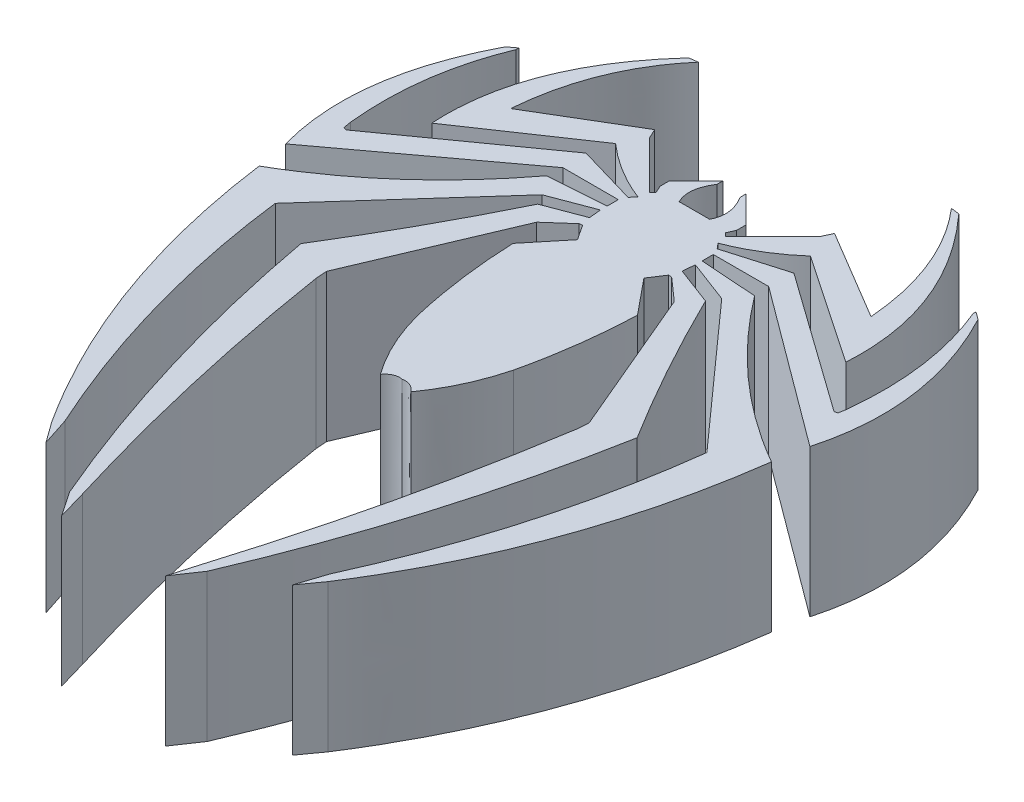
from build123d import *

# Parameters (mm, degrees)
BOSS_EXTRUDE1_DEPTH = 10


with BuildPart() as part:
    # Sketch1 → Boss-Extrude1 (new body)
    with BuildSketch(Plane(origin=(0, 0, 0), x_dir=(1, 0, 0), z_dir=(0, 1, 0))):
        with BuildLine():
            Line((-0.77475919, 17.805575817), (-0.77475919, 18.205472922))
            Line((-0.77475919, 18.205472922), (-2.591328104, 16.388904008))
            Line((-2.591328104, 16.388904008), (-2.591328104, 15.751300349))
            Line((-2.591328104, 15.751300349), (-2.362753208, 15.246029526))
            Line((-2.362753208, 15.246029526), (-2.591328104, 15.017454629))
            Line((-2.591328104, 15.017454629), (-5.779346397, 18.205472922))
            Line((-5.779346397, 18.205472922), (-6.095268046, 18.892889731))
            Line((-6.095268046, 18.892889731), (-12.218826377, 15.246029526))
            add(Edge.make_bspline(
                [(-12.218826377, 15.246029526), (-11.778721685, 20.620695324), (-8.581947184, 24.333309757)],
                knots=[0, 0, 0, 1, 1, 1], degree=2))
            Line((-8.581947184, 24.333309757), (-9.157047212, 24.259356466))
            add(Edge.make_bspline(
                [(-9.157047212, 24.259356466), (-14.447655818, 18.459017457), (-14.037673367, 11.71891231)],
                knots=[0, 0, 0, 1, 1, 1], degree=2))
            Line((-14.037673367, 11.71891231), (-6.606809824, 16.748676517))
            add(Edge.make_bspline(
                [(-6.606809824, 16.748676517), (-4.84160761, 15.196820639), (-2.713996128, 14.373140945)],
                knots=[0, 0, 0, 1, 1, 1], degree=2))
            Line((-2.713996128, 14.373140945), (-3.022885214, 14.011805458))
            Line((-3.022885214, 14.011805458), (-7.04843704, 15.185986651))
            Line((-7.04843704, 15.185986651), (-16.542260828, 8.414995079))
            Line((-16.542260828, 8.414995079), (-16.750184267, 8.475642613))
            Line((-16.750184267, 8.475642613), (-16.844000716, 8.999446115))
            add(Edge.make_bspline(
                [(-16.844000716, 8.999446115), (-17.398318859, 14.288056659), (-15.498292646, 18.892889731)],
                knots=[0, 0, 0, 0.937492037, 0.937492037, 0.937492037], degree=2))
            Line((-15.498292646, 18.892889731), (-15.498292646, 19.083480243))
            Line((-15.498292646, 19.083480243), (-16.018185643, 18.698181665))
            add(Edge.make_bspline(
                [(-16.018185643, 18.698181665), (-19.54860855, 11.964227915), (-17.772645014, 5.545401207)],
                knots=[0, 0, 0, 1, 1, 1], degree=2))
            Line((-17.772645014, 5.545401207), (-6.976425445, 13.546601594))
            Line((-6.976425445, 13.546601594), (-3.220749094, 13.546601594))
            Line((-3.220749094, 13.546601594), (-3.220749094, 12.787927187))
            Line((-3.220749094, 12.787927187), (-7.04843704, 12.523140875))
            add(Edge.make_bspline(
                [(-7.04843704, 12.523140875), (-11.378277138, 6.786058759), (-17.368277161, 3.344273399)],
                knots=[0, 0, 0, 1, 1, 1], degree=2))
            add(Edge.make_bspline(
                [(-17.368277161, 3.344273399), (-15.724066268, -8.863327627), (-9.366664211, -18.723496609)],
                knots=[0, 0, 0, 0.983877667, 0.983877667, 0.983877667], degree=2))
            Line((-9.366664211, -18.723496609), (-8.360846592, -20.115700618))
            Line((-8.360846592, -20.115700618), (-8.984631154, -18.211516166))
            add(Edge.make_bspline(
                [(-8.984631154, -18.211516166), (-13.367422275, -8.565356306), (-14.632198794, 1.702238546)],
                knots=[0, 0, 0, 0.96561084, 0.96561084, 0.96561084], degree=2))
            Line((-14.632198794, 1.702238546), (-6.095268046, 11.245692572))
            Line((-6.095268046, 11.245692572), (-3.220749094, 12.334656835))
            Line((-3.220749094, 12.334656835), (-3.137312332, 11.517506569))
            Line((-3.137312332, 11.517506569), (-5.68828216, 10.551113575))
            add(Edge.make_bspline(
                [(-5.68828216, 10.551113575), (-8.289822739, 5.230431142), (-11.398307003, 0.207327452)],
                knots=[0, 0, 0, 0.941866113, 0.941866113, 0.941866113], degree=2))
            add(Edge.make_bspline(
                [(-11.398307003, 0.207327452), (-9.259704318, -11.446844699), (-4.663293434, -22.207552312)],
                knots=[0, 0, 0, 0.984459997, 0.984459997, 0.984459997], degree=2))
            Line((-4.663293434, -22.207552312), (-3.52644295, -23.884260193))
            Line((-3.52644295, -23.884260193), (-4.094868192, -21.920639742))
            add(Edge.make_bspline(
                [(-4.094868192, -21.920639742), (-7.201743798, -11.767427454), (-8.842724338, -1.332659634)],
                knots=[0, 0, 0, 0.95775591, 0.95775591, 0.95775591], degree=2))
            Line((-8.842724338, -1.332659634), (-8.901419383, -0.55237788))
            Line((-8.901419383, -0.55237788), (-4.663293434, 9.459890703))
            Line((-4.663293434, 9.459890703), (-3.137312332, 10.808717055))
            Line((-3.137312332, 10.808717055), (-2.918598052, 10.825169375))
            Line((-2.918598052, 10.825169375), (-2.254002061, 9.809392881))
            Line((-2.254002061, 9.809392881), (-4.219363172, 7.408826128))
            add(Edge.make_bspline(
                [(-4.219363172, 7.408826128), (-4.079064375, 3.638553555), (-3.236682616, 0)],
                knots=[0, 0, 0, 0.892205795, 0.892205795, 0.892205795], degree=2))
            add(Edge.make_bspline(
                [(-3.236682616, 0), (-2.55670829, -2.640008962), (-1.031376318, -4.773443308)],
                knots=[0, 0, 0, 0.876843131, 0.876843131, 0.876843131], degree=2))
            add(Edge.make_bspline(
                [(-1.031376318, -4.773443308), (-0.582556801, -4.206513749), (0, -4.327217184)],
                knots=[0, 0, 0, 1, 1, 1], degree=2))
            add(Edge.make_bspline(
                [(1.031376318, -4.773443308), (0.582556801, -4.206513749), (0, -4.327217184)],
                knots=[0, 0, 0, 1, 1, 1], degree=2))
            add(Edge.make_bspline(
                [(3.236682616, 0), (2.55670829, -2.640008962), (1.031376318, -4.773443308)],
                knots=[0, 0, 0, 0.876843131, 0.876843131, 0.876843131], degree=2))
            add(Edge.make_bspline(
                [(4.219363172, 7.408826128), (4.079064375, 3.638553555), (3.236682616, 0)],
                knots=[0, 0, 0, 0.892205795, 0.892205795, 0.892205795], degree=2))
            Line((4.219363172, 7.408826128), (2.254002061, 9.809392881))
            Line((2.254002061, 9.809392881), (2.918598052, 10.825169375))
            Line((2.918598052, 10.825169375), (3.137312332, 10.808717055))
            Line((3.137312332, 10.808717055), (4.663293434, 9.459890703))
            Line((4.663293434, 9.459890703), (8.901419383, -0.55237788))
            Line((8.901419383, -0.55237788), (8.842724338, -1.332659634))
            add(Edge.make_bspline(
                [(4.094868192, -21.920639742), (7.201743798, -11.767427454), (8.842724338, -1.332659634)],
                knots=[0, 0, 0, 0.95775591, 0.95775591, 0.95775591], degree=2))
            Line((4.094868192, -21.920639742), (3.52644295, -23.884260193))
            Line((3.52644295, -23.884260193), (4.663293434, -22.207552312))
            add(Edge.make_bspline(
                [(11.398307003, 0.207327452), (9.259704318, -11.446844699), (4.663293434, -22.207552312)],
                knots=[0, 0, 0, 0.984459997, 0.984459997, 0.984459997], degree=2))
            add(Edge.make_bspline(
                [(5.68828216, 10.551113575), (8.289822739, 5.230431142), (11.398307003, 0.207327452)],
                knots=[0, 0, 0, 0.941866113, 0.941866113, 0.941866113], degree=2))
            Line((5.68828216, 10.551113575), (3.137312332, 11.517506569))
            Line((3.137312332, 11.517506569), (3.220749094, 12.334656835))
            Line((3.220749094, 12.334656835), (6.095268046, 11.245692572))
            Line((6.095268046, 11.245692572), (14.632198794, 1.702238546))
            add(Edge.make_bspline(
                [(8.984631154, -18.211516166), (13.367422275, -8.565356306), (14.632198794, 1.702238546)],
                knots=[0, 0, 0, 0.96561084, 0.96561084, 0.96561084], degree=2))
            Line((8.984631154, -18.211516166), (8.360846592, -20.115700618))
            Line((8.360846592, -20.115700618), (9.366664211, -18.723496609))
            add(Edge.make_bspline(
                [(17.368277161, 3.344273399), (15.724066268, -8.863327627), (9.366664211, -18.723496609)],
                knots=[0, 0, 0, 0.983877667, 0.983877667, 0.983877667], degree=2))
            add(Edge.make_bspline(
                [(7.04843704, 12.523140875), (11.378277138, 6.786058759), (17.368277161, 3.344273399)],
                knots=[0, 0, 0, 1, 1, 1], degree=2))
            Line((7.04843704, 12.523140875), (3.220749094, 12.787927187))
            Line((3.220749094, 12.787927187), (3.220749094, 13.546601594))
            Line((3.220749094, 13.546601594), (6.976425445, 13.546601594))
            Line((6.976425445, 13.546601594), (17.772645014, 5.545401207))
            add(Edge.make_bspline(
                [(16.018185643, 18.698181665), (19.54860855, 11.964227915), (17.772645014, 5.545401207)],
                knots=[0, 0, 0, 1, 1, 1], degree=2))
            Line((16.018185643, 18.698181665), (15.498292646, 19.083480243))
            Line((15.498292646, 19.083480243), (15.498292646, 18.892889731))
            add(Edge.make_bspline(
                [(16.844000716, 8.999446115), (17.398318859, 14.288056659), (15.498292646, 18.892889731)],
                knots=[0, 0, 0, 0.937492037, 0.937492037, 0.937492037], degree=2))
            Line((16.844000716, 8.999446115), (16.750184267, 8.475642613))
            Line((16.750184267, 8.475642613), (16.542260828, 8.414995079))
            Line((16.542260828, 8.414995079), (7.04843704, 15.185986651))
            Line((7.04843704, 15.185986651), (3.022885214, 14.011805458))
            Line((3.022885214, 14.011805458), (2.713996128, 14.373140945))
            add(Edge.make_bspline(
                [(6.606809824, 16.748676517), (4.84160761, 15.196820639), (2.713996128, 14.373140945)],
                knots=[0, 0, 0, 1, 1, 1], degree=2))
            Line((6.606809824, 16.748676517), (14.037673367, 11.71891231))
            add(Edge.make_bspline(
                [(9.157047212, 24.259356466), (14.447655818, 18.459017457), (14.037673367, 11.71891231)],
                knots=[0, 0, 0, 1, 1, 1], degree=2))
            Line((9.157047212, 24.259356466), (8.581947184, 24.333309757))
            add(Edge.make_bspline(
                [(12.218826377, 15.246029526), (11.778721685, 20.620695324), (8.581947184, 24.333309757)],
                knots=[0, 0, 0, 1, 1, 1], degree=2))
            Line((12.218826377, 15.246029526), (6.095268046, 18.892889731))
            Line((6.095268046, 18.892889731), (5.779346397, 18.205472922))
            Line((5.779346397, 18.205472922), (2.591328104, 15.017454629))
            Line((2.591328104, 15.017454629), (2.362753208, 15.246029526))
            Line((2.362753208, 15.246029526), (2.591328104, 15.751300349))
            Line((2.591328104, 15.751300349), (2.591328104, 16.388904008))
            Line((2.591328104, 16.388904008), (0.77475919, 18.205472922))
            Line((0.77475919, 18.205472922), (0.77475919, 17.805575817))
            add(Edge.make_bspline(
                [(0.77475919, 17.805575817), (1.570165167, 16.532957411), (1.031376318, 15.489501362)],
                knots=[0, 0, 0, 1, 1, 1], degree=2))
            Line((1.031376318, 15.489501362), (-1.031376318, 15.489501362))
            add(Edge.make_bspline(
                [(-0.77475919, 17.805575817), (-1.570165167, 16.532957411), (-1.031376318, 15.489501362)],
                knots=[0, 0, 0, 1, 1, 1], degree=2))
        make_face()
    extrude(amount=BOSS_EXTRUDE1_DEPTH)


solid = part.part
